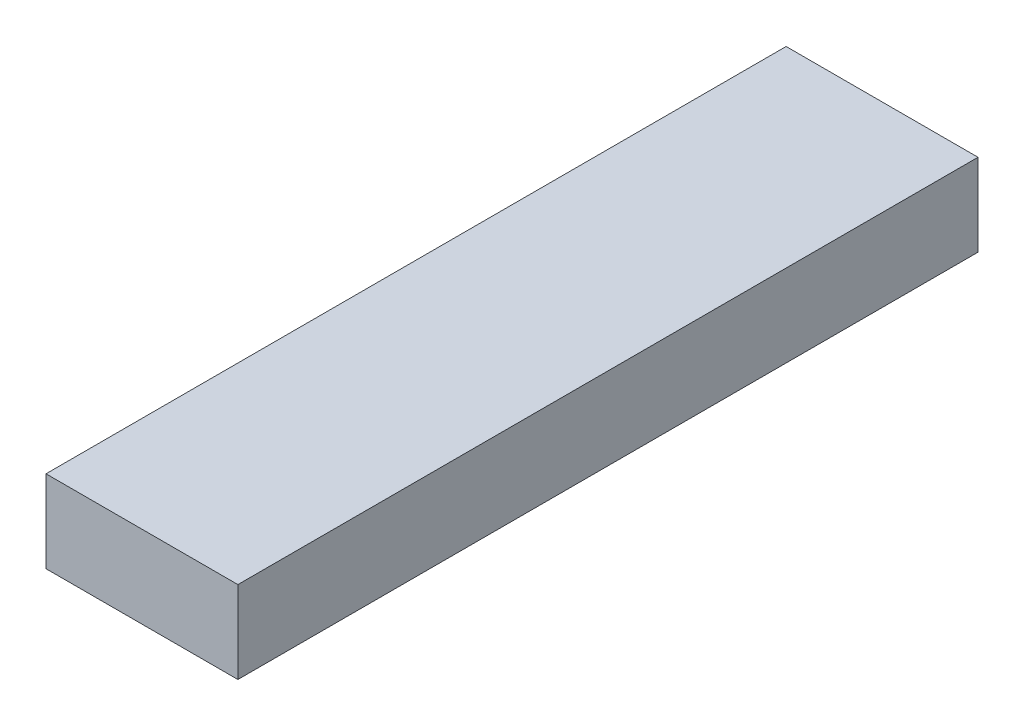
from build123d import *

# Parameters (mm, degrees)
SKETCH2_W           = 88.9
SKETCH2_H           = 342.9
BOSS_EXTRUDE3_DEPTH = 38.1


with BuildPart() as part:
    # Sketch2 → Boss-Extrude3 (new body)
    with BuildSketch(Plane(origin=(0, 0, 0), x_dir=(1, 0, 0), z_dir=(0, 1, 0))):
        with Locations((44.45, 171.45)):
            Rectangle(SKETCH2_W, SKETCH2_H)
    extrude(amount=BOSS_EXTRUDE3_DEPTH)


solid = part.part
